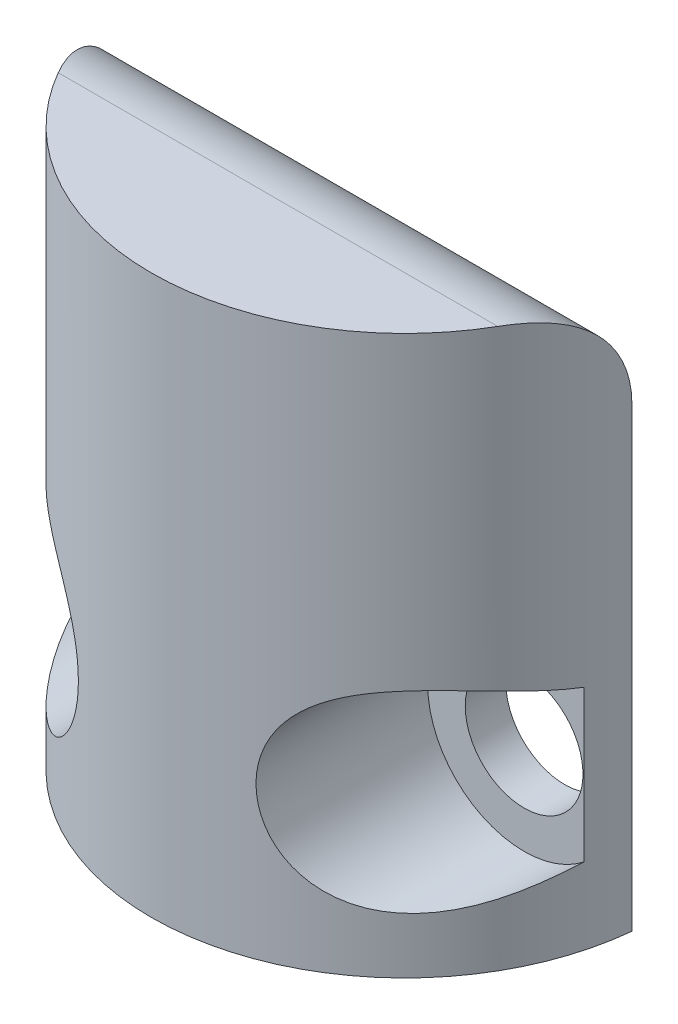
from build123d import *

# Parameters (mm, degrees)
BOSS_EXTRUDE1_DEPTH = 13.97
FILLET1_R           = 2.54
SKETCH4_R           = 1.4732
CUT_EXTRUDE1_DEPTH  = 6.7150001
SKETCH6_R           = 2.413
CUT_EXTRUDE3_DEPTH  = 5.334


with BuildPart() as part:
    # Sketch3 → Boss-Extrude1 (new body)
    with BuildSketch(Plane.XZ.offset(12.7)):
        with BuildLine():
            ThreePointArc((6.318170226, 0.635), (0, 6.35), (-6.318170226, 0.635))
            Line((-6.318170226, 0.635), (6.318170226, 0.635))
        make_face()
    extrude(amount=-BOSS_EXTRUDE1_DEPTH)

    # Fillet1
    fillet1_edges = [part.edges().sort_by_distance(p)[0] for p in [
        (0, 1.27, 0.635),
    ]]
    fillet(fillet1_edges, radius=FILLET1_R)

    # Sketch4 → Cut-Extrude1 (cut, through all)
    with BuildSketch(Plane(origin=(0, 0, 0.635), x_dir=(-1, 0, 0), z_dir=(0, 0, -1))):
        with Locations((4.6355, -8.89)):
            Circle(SKETCH4_R)
        with Locations((-4.6355, -8.89)):
            Circle(SKETCH4_R)
    extrude(amount=-CUT_EXTRUDE1_DEPTH, mode=Mode.SUBTRACT)

    # Sketch6 → Cut-Extrude3 (cut)
    with BuildSketch(Plane(origin=(0, 0, 6.985), x_dir=(-1, 0, 0), z_dir=(0, 0, -1))):
        with Locations((4.6355, -8.89)):
            Circle(SKETCH6_R)
        with Locations((-4.6355, -8.89)):
            Circle(SKETCH6_R)
    extrude(amount=CUT_EXTRUDE3_DEPTH, mode=Mode.SUBTRACT)


solid = part.part
